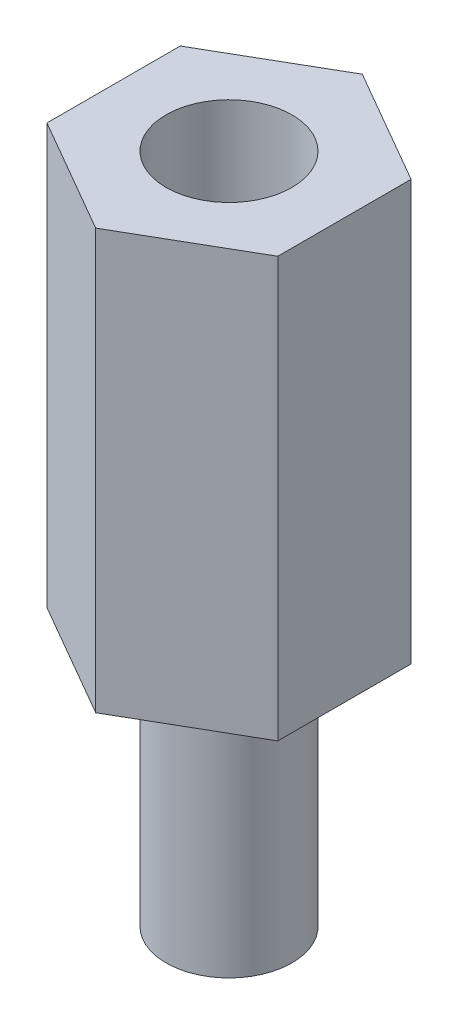
from build123d import *

# Parameters (mm, degrees)
SALIENTE_EXTRUIR1_DEPTH = 10
CROQUIS2_R              = 1.5
SALIENTE_EXTRUIR2_DEPTH = 6
CROQUIS3_R              = 1.5
CORTAR_EXTRUIR1_DEPTH   = 6


with BuildPart() as part:
    # Croquis1 → Saliente-Extruir1 (new body)
    with BuildSketch(Plane(origin=(0, 0, 0), x_dir=(1, 0, 0), z_dir=(0, 1, 0))):
        Polygon((0, 3.175426481), (-2.75, 1.58771324), (-2.75, -1.58771324), (0, -3.175426481), (2.75, -1.58771324), (2.75, 1.58771324), align=None)
    extrude(amount=SALIENTE_EXTRUIR1_DEPTH)

    # Croquis2 → Saliente-Extruir2 (add)
    with BuildSketch(Plane.XZ):
        Circle(CROQUIS2_R)
    extrude(amount=SALIENTE_EXTRUIR2_DEPTH)

    # Croquis3 → Cortar-Extruir1 (cut)
    with BuildSketch(Plane(origin=(0, 10, 0), x_dir=(1, 0, 0), z_dir=(0, 1, 0))):
        Circle(CROQUIS3_R)
    extrude(amount=-CORTAR_EXTRUIR1_DEPTH, mode=Mode.SUBTRACT)


solid = part.part
